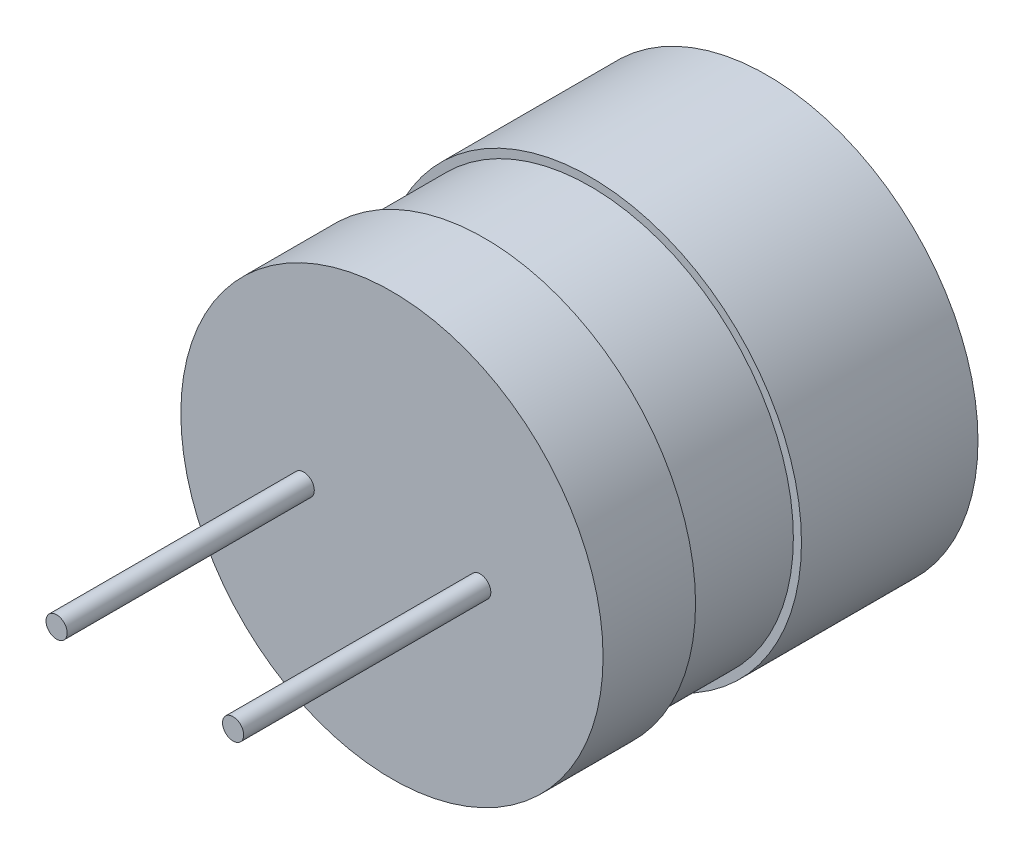
from build123d import *

# Parameters (mm, degrees)
SKETCH1_R           = 5.98
BOSS_EXTRUDE1_DEPTH = 5
SKETCH2_R           = 1.25
CUT_EXTRUDE1_DEPTH  = 5
SKETCH3_R           = 5.75
BOSS_EXTRUDE2_DEPTH = 3
SKETCH4_R           = 5.98
BOSS_EXTRUDE3_DEPTH = 2.62
SKETCH5_R           = 0.645
BOSS_EXTRUDE4_DEPTH = 7
SKETCH6_R           = 0.645
SKETCH6_R_2         = 0.3
CUT_EXTRUDE2_DEPTH  = 7


with BuildPart() as part:
    # Sketch1 → Boss-Extrude1 (new body)
    with BuildSketch(Plane.XY):
        Circle(SKETCH1_R)
    extrude(amount=BOSS_EXTRUDE1_DEPTH)

    # Sketch2 → Cut-Extrude1 (cut)
    with BuildSketch(Plane(origin=(0, 0, 0), x_dir=(-1, 0, 0), z_dir=(0, 0, -1))):
        Circle(SKETCH2_R)
    extrude(amount=-CUT_EXTRUDE1_DEPTH, mode=Mode.SUBTRACT)

    # Sketch3 → Boss-Extrude2 (add)
    with BuildSketch(Plane.XY.offset(5)):
        Circle(SKETCH3_R)
    extrude(amount=BOSS_EXTRUDE2_DEPTH)

    # Sketch4 → Boss-Extrude3 (add)
    with BuildSketch(Plane.XY.offset(8)):
        Circle(SKETCH4_R)
    extrude(amount=BOSS_EXTRUDE3_DEPTH)

    # Sketch5 → Boss-Extrude4 (add)
    with BuildSketch(Plane.XY.offset(10.62)):
        with Locations((-2.5, 0)):
            Circle(SKETCH5_R)
        with Locations((2.5, 0)):
            Circle(SKETCH5_R)
    extrude(amount=BOSS_EXTRUDE4_DEPTH)

    # Sketch6 → Cut-Extrude2 (cut)
    with BuildSketch(Plane.XY.offset(17.62)):
        with Locations((-2.5, 0)):
            Circle(SKETCH6_R)
        with Locations((-2.5, 0)):
            Circle(SKETCH6_R_2, mode=Mode.SUBTRACT)
        with Locations((2.5, 0)):
            Circle(SKETCH6_R)
        with Locations((2.5, 0)):
            Circle(SKETCH6_R_2, mode=Mode.SUBTRACT)
    extrude(amount=-CUT_EXTRUDE2_DEPTH, mode=Mode.SUBTRACT)


solid = part.part
